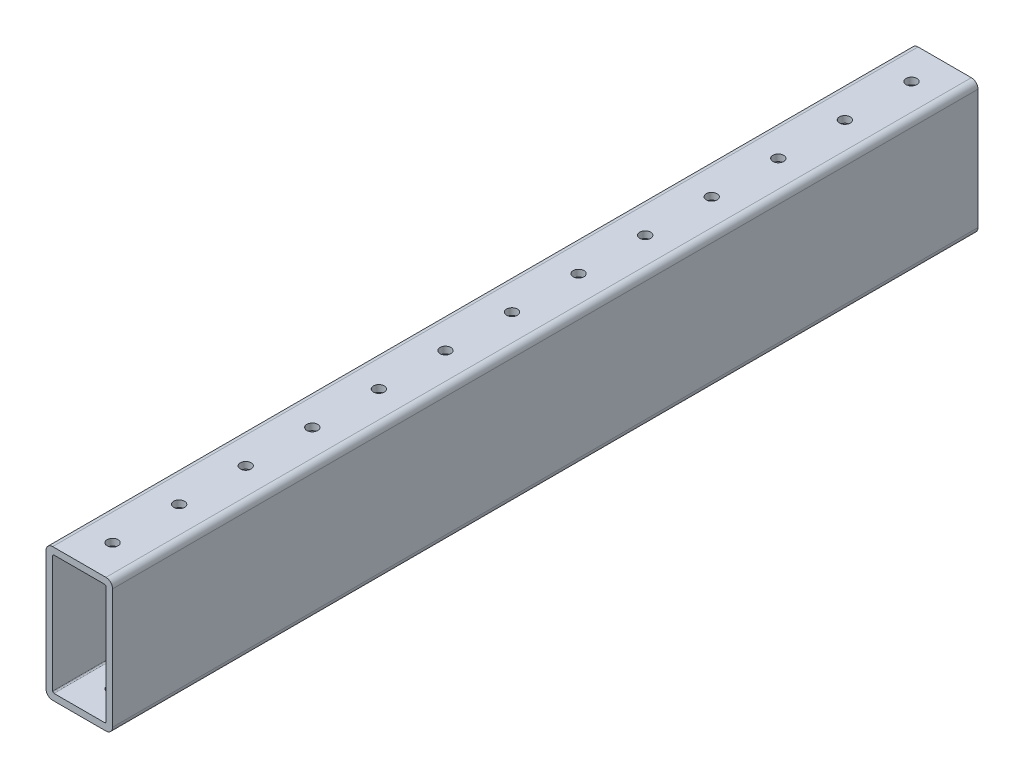
from build123d import *

# Parameters (mm, degrees)
SKETCH1_W                 = 330.2
SKETCH1_H                 = 50.8
BOSS_EXTRUDE1_DEPTH       = 25.4
SKETCH2_W                 = 20.32
SKETCH2_H                 = 45.72
CUT_EXTRUDE1_DEPTH        = 331.2
F_6_CLEARANCE_HOLE1_D     = 4.1402
F_6_CLEARANCE_HOLE1_DEPTH = 50.8
F_6_CLEARANCE_HOLE2_D     = 4.1402
F_6_CLEARANCE_HOLE2_DEPTH = 50.8
FILLET1_R                 = 0.5
FILLET2_R                 = 2.54


with BuildPart() as part:
    # Sketch1 → Boss-Extrude1 (new body)
    with BuildSketch(Plane(origin=(12.7, 0, 0), x_dir=(0, 0, -1), z_dir=(1, 0, 0))):
        Rectangle(SKETCH1_W, SKETCH1_H)
    extrude(amount=-BOSS_EXTRUDE1_DEPTH)

    # Sketch2 → Cut-Extrude1 (cut, through all)
    with BuildSketch(Plane(origin=(0, 0, -165.1), x_dir=(-1, 0, 0), z_dir=(0, 0, -1))):
        Rectangle(SKETCH2_W, SKETCH2_H)
    extrude(amount=-CUT_EXTRUDE1_DEPTH, mode=Mode.SUBTRACT)

    # #6 Clearance Hole1
    with Locations(Plane(origin=(0, -25.4, 0), x_dir=(-1, 0, 0), z_dir=(0, -1, 0))):
        with Locations((0, 711.2), (0, 736.6), (0, 685.8), (0, 660.4), (0, 635), (0, 609.6), (0, 584.2), (0, 558.8), (0, 533.4), (0, 508), (0, 482.6), (0, 457.2), (0, 431.8), (0, 406.4), (0, 381), (0, 355.6), (0, 330.2), (0, 304.8), (0, 279.4), (0, 254), (0, 228.6), (0, 203.2), (0, 177.8), (0, 152.4), (0, 127), (0, 101.6), (0, 76.2), (0, 50.8), (0, 25.4), (0, 0), (0, -25.4), (0, -50.8), (0, -76.2), (0, -101.6), (0, -127), (0, -152.4), (0, -177.8), (0, -203.2), (0, -228.6), (0, -254), (0, -279.4), (0, -304.8), (0, -330.2), (0, -355.6), (0, -381), (0, -406.4), (0, -431.8), (0, -457.2), (0, -482.6), (0, -508), (0, -533.4), (0, -558.8), (0, -584.2), (0, -609.6), (0, -635), (0, -660.4), (0, -685.8), (0, -711.2), (0, -736.6)):
            Hole(F_6_CLEARANCE_HOLE1_D / 2, depth=F_6_CLEARANCE_HOLE1_DEPTH)

    # #6 Clearance Hole2
    with Locations(Plane(origin=(0, 25.4, 0), x_dir=(1, 0, 0), z_dir=(0, 1, 0))):
        with Locations((0, 711.2), (0, 736.6), (0, 685.8), (0, 660.4), (0, 635), (0, 609.6), (0, 584.2), (0, 558.8), (0, 533.4), (0, 508), (0, 482.6), (0, 457.2), (0, 431.8), (0, 406.4), (0, 381), (0, 355.6), (0, 330.2), (0, 304.8), (0, 279.4), (0, 254), (0, 228.6), (0, 203.2), (0, 177.8), (0, 152.4), (0, 127), (0, 101.6), (0, 76.2), (0, 50.8), (0, 25.4), (0, 0), (0, -25.4), (0, -50.8), (0, -76.2), (0, -101.6), (0, -127), (0, -152.4), (0, -177.8), (0, -203.2), (0, -228.6), (0, -254), (0, -279.4), (0, -304.8), (0, -330.2), (0, -355.6), (0, -381), (0, -406.4), (0, -431.8), (0, -457.2), (0, -482.6), (0, -508), (0, -533.4), (0, -558.8), (0, -584.2), (0, -609.6), (0, -635), (0, -660.4), (0, -685.8), (0, -711.2), (0, -736.6)):
            Hole(F_6_CLEARANCE_HOLE2_D / 2, depth=F_6_CLEARANCE_HOLE2_DEPTH)

    # Fillet1
    fillet1_edges = [part.edges().sort_by_distance(p)[0] for p in [
        (-10.16, -22.86, 0),
        (10.16, -22.86, 0),
        (10.16, 22.86, 0),
        (-10.16, 22.86, 0),
    ]]
    fillet(fillet1_edges, radius=FILLET1_R)

    # Fillet2
    fillet2_edges = [part.edges().sort_by_distance(p)[0] for p in [
        (-12.7, 25.4, 0),
        (-12.7, -25.4, 0),
        (12.7, 25.4, 0),
        (12.7, -25.4, 0),
    ]]
    fillet(fillet2_edges, radius=FILLET2_R)


solid = part.part
